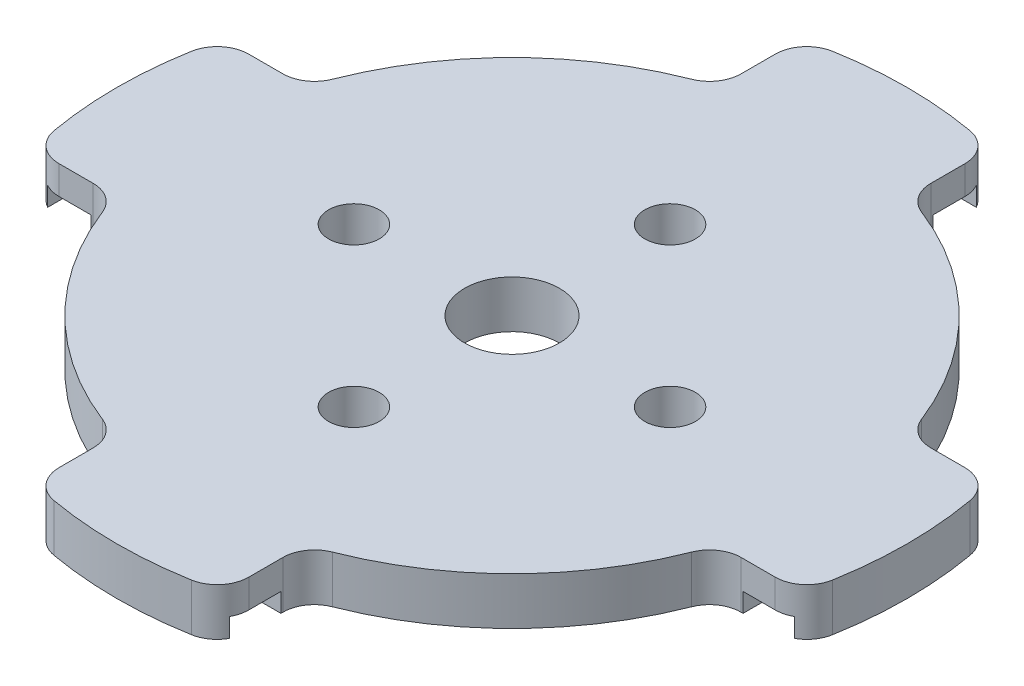
from build123d import *

# Parameters (mm, degrees)
SKIZZE1_R                       = 19
SKIZZE1_R_2                     = 1.6
AUFSATZ_LINEAR_AUSTRAGEN1_DEPTH = 3
SKIZZE6_R                       = 3
SCHNITT_LINEAR_AUSTRAGEN2_DEPTH = 36.482389998
SKIZZE7_W                       = 3
SKIZZE7_H                       = 12
SKIZZE7_W_2                     = 12
SKIZZE7_H_2                     = 3
SCHNITT_LINEAR_AUSTRAGEN3_DEPTH = 1.2


with BuildPart() as part:
    # Skizze1 → Aufsatz-Linear austragen1 (new body)
    with BuildSketch(Plane(origin=(0, 0, 0), x_dir=(1, 0, 0), z_dir=(0, 1, 0))):
        with BuildLine():
            ThreePointArc((6, -20.493901532), (6.348554352, -19.365749382), (7.272727273, -18.630819574))
            ThreePointArc((7.272727273, -18.630819574), (14.142135624, -14.142135624), (18.630819574, -7.272727273))
            ThreePointArc((18.630819574, -7.272727273), (19.365749382, -6.348554352), (20.493901532, -6))
            Line((20.493901532, -6), (22.649503306, -6))
            ThreePointArc((22.649503306, -6), (23.93487248, -5.532261755), (24.619025332, -4.347826087))
            ThreePointArc((24.619025332, -4.347826087), (25, 0), (24.619025332, 4.347826087))
            ThreePointArc((24.619025332, 4.347826087), (23.93487248, 5.532261755), (22.649503306, 6))
            Line((22.649503306, 6), (20.493901532, 6))
            ThreePointArc((20.493901532, 6), (19.365749382, 6.348554352), (18.630819574, 7.272727273))
            ThreePointArc((18.630819574, 7.272727273), (14.142135624, 14.142135624), (7.272727273, 18.630819574))
            ThreePointArc((7.272727273, 18.630819574), (6.348554352, 19.365749382), (6, 20.493901532))
            Line((6, 20.493901532), (6, 22.649503306))
            ThreePointArc((6, 22.649503306), (5.532261755, 23.93487248), (4.347826087, 24.619025332))
            ThreePointArc((4.347826087, 24.619025332), (0, 25), (-4.347826087, 24.619025332))
            ThreePointArc((-4.347826087, 24.619025332), (-5.532261755, 23.93487248), (-6, 22.649503306))
            Line((-6, 22.649503306), (-6, 20.493901532))
            ThreePointArc((-6, 20.493901532), (-6.348554352, 19.365749382), (-7.272727273, 18.630819574))
            ThreePointArc((-7.272727273, 18.630819574), (-14.142135624, 14.142135624), (-18.630819574, 7.272727273))
            ThreePointArc((-18.630819574, 7.272727273), (-19.365749382, 6.348554352), (-20.493901532, 6))
            Line((-20.493901532, 6), (-22.649503306, 6))
            ThreePointArc((-22.649503306, 6), (-23.93487248, 5.532261755), (-24.619025332, 4.347826087))
            ThreePointArc((-24.619025332, 4.347826087), (-25, 0), (-24.619025332, -4.347826087))
            ThreePointArc((-24.619025332, -4.347826087), (-23.93487248, -5.532261755), (-22.649503306, -6))
            Line((-22.649503306, -6), (-20.493901532, -6))
            ThreePointArc((-20.493901532, -6), (-19.365749382, -6.348554352), (-18.630819574, -7.272727273))
            ThreePointArc((-18.630819574, -7.272727273), (-14.142135624, -14.142135624), (-7.272727273, -18.630819574))
            ThreePointArc((-7.272727273, -18.630819574), (-6.348554352, -19.365749382), (-6, -20.493901532))
            Line((-6, -20.493901532), (-6, -22.649503306))
            ThreePointArc((-6, -22.649503306), (-5.532261755, -23.93487248), (-4.347826087, -24.619025332))
            ThreePointArc((-4.347826087, -24.619025332), (0, -25), (4.347826087, -24.619025332))
            ThreePointArc((4.347826087, -24.619025332), (5.532261755, -23.93487248), (6, -22.649503306))
            Line((6, -22.649503306), (6, -20.493901532))
        make_face()
        Circle(SKIZZE1_R, mode=Mode.SUBTRACT)
        Circle(SKIZZE1_R)
        with Locations(Location((0, -10, 0), (0, 0, 270))):
            Circle(SKIZZE1_R_2, mode=Mode.SUBTRACT)
        with Locations(Location((-10, 0, 0), (0, 0, 270))):
            Circle(SKIZZE1_R_2, mode=Mode.SUBTRACT)
        with Locations(Location((10, 0, 0), (0, 0, 270))):
            Circle(SKIZZE1_R_2, mode=Mode.SUBTRACT)
        with Locations(Location((0, 10, 0), (0, 0, 270))):
            Circle(SKIZZE1_R_2, mode=Mode.SUBTRACT)
        with Locations(Location((0, 0, 0), (0, 0, 270))):
            Circle(SKIZZE1_R_2, mode=Mode.SUBTRACT)
    extrude(amount=AUFSATZ_LINEAR_AUSTRAGEN1_DEPTH)

    # Skizze6 → Schnitt-Linear austragen2 (cut, through all)
    with BuildSketch(Plane.XZ):
        with Locations(Location((0, 0, 0), (0, 0, 270))):
            Circle(SKIZZE6_R)
    extrude(amount=-SCHNITT_LINEAR_AUSTRAGEN2_DEPTH, mode=Mode.SUBTRACT)

    # Skizze7 → Schnitt-Linear austragen3 (cut)
    with BuildSketch(Plane.XZ):
        with Locations((-22.119025332, 0)):
            Rectangle(SKIZZE7_W, SKIZZE7_H)
        with Locations((0, 22.119025332)):
            Rectangle(SKIZZE7_W_2, SKIZZE7_H_2)
        with Locations((22.119025332, 0)):
            Rectangle(SKIZZE7_W, SKIZZE7_H)
        with Locations((0, -22.119025332)):
            Rectangle(SKIZZE7_W_2, SKIZZE7_H_2)
    extrude(amount=-SCHNITT_LINEAR_AUSTRAGEN3_DEPTH, mode=Mode.SUBTRACT)


solid = part.part
